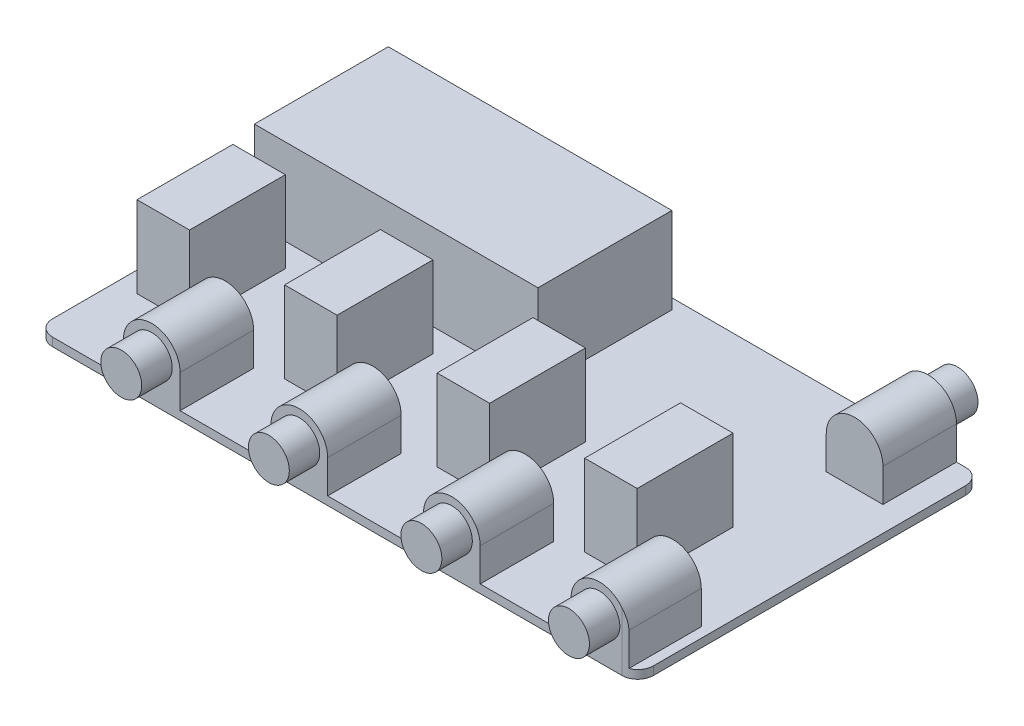
from build123d import *

# Parameters (mm, degrees)
ESQUISSE1_W                          = 114.45
ESQUISSE1_H                          = 65.45
BOSS_EXTRU_1_DEPTH                   = 1.6
BOSS_EXTRU_2_DEPTH                   = 14
ESQUISSE3_R                          = 3.9
BOSS_EXTRU_3_DEPTH                   = 5.8
ESQUISSE6_W                          = 10
ESQUISSE6_H                          = 18.25
BOSS_EXTRU_6_DEPTH                   = 15.5
R_P_TITION_LIN_AIRE1_COUNT           = 2
R_P_TITION_LIN_AIRE1_PITCH           = 28.1
R_P_TITION_LIN_AIRE2_COUNT           = 2
R_P_TITION_LIN_AIRE2_PITCH           = 57.15
R_P_TITION_LIN_AIRE2_COPY_1_DEPTH    = 14
R_P_TITION_LIN_AIRE2_COPY_2_SKETCH_R = 3.9
R_P_TITION_LIN_AIRE2_COPY_2_DEPTH    = 5.8
R_P_TITION_LIN_AIRE2_COPY_3_SKETCH_W = 10
R_P_TITION_LIN_AIRE2_COPY_3_SKETCH_H = 18.25
R_P_TITION_LIN_AIRE2_COPY_3_DEPTH    = 15.5
BOSS_EXTRU_4_DEPTH                   = 14
ESQUISSE5_R                          = 3.9
BOSS_EXTRU_5_DEPTH                   = 5.6
CONG_1_R                             = 3
ESQUISSE7_W                          = 54
ESQUISSE7_H                          = 25.5
BOSS_EXTRU_7_DEPTH                   = 16.4


with BuildPart() as part:
    # Esquisse1 → Boss.-Extru.1 (new body)
    with BuildSketch(Plane(origin=(0, 0, 0), x_dir=(1, 0, 0), z_dir=(0, 1, 0))):
        Rectangle(ESQUISSE1_W, ESQUISSE1_H)
    extrude(amount=BOSS_EXTRU_1_DEPTH)

    # Esquisse2 → Boss.-Extru.2 (add)
    with BuildSketch(Plane.XY.offset(32.725)):
        with BuildLine():
            Line((44.525, 1.6), (55.325, 1.6))
            Line((55.325, 1.6), (55.325, 7.9))
            ThreePointArc((55.325, 7.9), (49.925, 13.3), (44.525, 7.9))
            Line((44.525, 7.9), (44.525, 1.6))
        make_face()
    boss_extru_2 = extrude(amount=-BOSS_EXTRU_2_DEPTH)

    # Esquisse3 → Boss.-Extru.3 (add)
    with BuildSketch(Plane.XY.offset(32.725)):
        with Locations((49.925, 7.9)):
            Circle(ESQUISSE3_R)
    boss_extru_3 = extrude(amount=BOSS_EXTRU_3_DEPTH)

    # Esquisse6 → Boss.-Extru.6 (add)
    with BuildSketch(Plane(origin=(0, 1.6, 0), x_dir=(1, 0, 0), z_dir=(0, 1, 0))):
        with Locations((36.925, -8.4)):
            Rectangle(ESQUISSE6_W, ESQUISSE6_H)
    boss_extru_6 = extrude(amount=BOSS_EXTRU_6_DEPTH)

    # Répétition linéaire1: Boss.-Extru.2, Boss.-Extru.3, Boss.-Extru.6 ×2
    with Locations(*[(-i * R_P_TITION_LIN_AIRE1_PITCH, 0, 0) for i in range(1, R_P_TITION_LIN_AIRE1_COUNT)]):
        add(boss_extru_2)
        add(boss_extru_3)
        add(boss_extru_6)

    # Répétition linéaire2: Boss.-Extru.2, Boss.-Extru.3, Boss.-Extru.6 ×2
    with Locations(*[(-i * R_P_TITION_LIN_AIRE2_PITCH, 0, 0) for i in range(1, R_P_TITION_LIN_AIRE2_COUNT)]):
        add(boss_extru_2)
        add(boss_extru_3)
        add(boss_extru_6)

    # Répétition linéaire2 copy 1 sketch → Répétition linéaire2 copy 1 (add)
    with BuildSketch(Plane(origin=(-85.25, 0, 32.725), x_dir=(1, 0, 0), z_dir=(0, 0, 1))):
        with BuildLine():
            Line((44.525, 1.6), (55.325, 1.6))
            Line((55.325, 1.6), (55.325, 7.9))
            ThreePointArc((55.325, 7.9), (49.925, 13.3), (44.525, 7.9))
            Line((44.525, 7.9), (44.525, 1.6))
        make_face()
    extrude(amount=-R_P_TITION_LIN_AIRE2_COPY_1_DEPTH)

    # Répétition linéaire2 copy 2 sketch → Répétition linéaire2 copy 2 (add)
    with BuildSketch(Plane(origin=(-85.25, 0, 32.725), x_dir=(1, 0, 0), z_dir=(0, 0, 1))):
        with Locations((49.925, 7.9)):
            Circle(R_P_TITION_LIN_AIRE2_COPY_2_SKETCH_R)
    extrude(amount=R_P_TITION_LIN_AIRE2_COPY_2_DEPTH)

    # Répétition linéaire2 copy 3 sketch → Répétition linéaire2 copy 3 (add)
    with BuildSketch(Plane(origin=(-85.25, 1.6, 0), x_dir=(1, 0, 0), z_dir=(0, 1, 0))):
        with Locations((36.925, -8.4)):
            Rectangle(R_P_TITION_LIN_AIRE2_COPY_3_SKETCH_W, R_P_TITION_LIN_AIRE2_COPY_3_SKETCH_H)
    extrude(amount=R_P_TITION_LIN_AIRE2_COPY_3_DEPTH)

    # Esquisse4 → Boss.-Extru.4 (add)
    with BuildSketch(Plane(origin=(0, 0, -32.725), x_dir=(-1, 0, 0), z_dir=(0, 0, -1))):
        with BuildLine():
            Line((-41.675, 1.6), (-52.475, 1.6))
            Line((-52.475, 1.6), (-52.475, 7.9))
            ThreePointArc((-52.475, 7.9), (-47.075, 13.3), (-41.675, 7.9))
            Line((-41.675, 7.9), (-41.675, 1.6))
        make_face()
    extrude(amount=-BOSS_EXTRU_4_DEPTH)

    # Esquisse5 → Boss.-Extru.5 (add)
    with BuildSketch(Plane(origin=(0, 0, -32.725), x_dir=(-1, 0, 0), z_dir=(0, 0, -1))):
        with Locations((-47.075, 7.9)):
            Circle(ESQUISSE5_R)
    extrude(amount=BOSS_EXTRU_5_DEPTH)

    # Congé1
    cong_1_edges = [part.edges().sort_by_distance(p)[0] for p in [
        (57.225, 0.8, -32.725),
        (-57.225, 0.8, -32.725),
        (-57.225, 0.8, 32.725),
        (57.225, 0.8, 32.725),
    ]]
    fillet(cong_1_edges, radius=CONG_1_R)

    # Esquisse7 → Boss.-Extru.7 (add)
    with BuildSketch(Plane(origin=(0, 1.6, 0), x_dir=(1, 0, 0), z_dir=(0, 1, 0))):
        with Locations((-26.725, 17.975)):
            Rectangle(ESQUISSE7_W, ESQUISSE7_H)
    extrude(amount=BOSS_EXTRU_7_DEPTH)


solid = part.part
